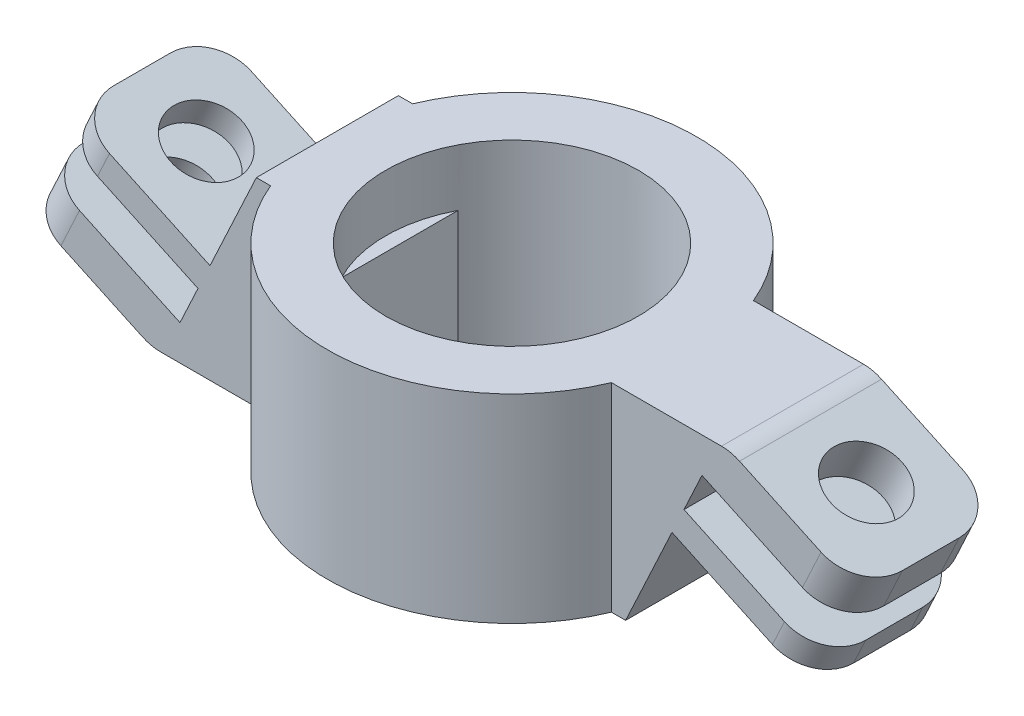
from build123d import *

# Parameters (mm, degrees)
SKETCH1_R           = 6.5
BOSS_EXTRUDE1_DEPTH = 7
BOSS_EXTRUDE2_DEPTH = 2.5
SKETCH3_R           = 1.25
CUT_EXTRUDE1_DEPTH  = 17.888639434
SKETCH4_R           = 1.25
CUT_EXTRUDE2_DEPTH  = 17.888639434
FILLET1_R           = 1.5
SKETCH5_R           = 4.45
CUT_EXTRUDE3_DEPTH  = 2


with BuildPart() as part:
    # Sketch1 → Boss-Extrude1 (new body)
    with BuildSketch(Plane(origin=(0, 0, 0), x_dir=(1, 0, 0), z_dir=(0, 1, 0))):
        Circle(SKETCH1_R)
        with BuildLine():
            Line((-3.95, 2.049390153), (-3.95, -2.049390153))
            ThreePointArc((-3.95, -2.049390153), (0, -4.45), (3.95, -2.049390153))
            Line((3.95, -2.049390153), (3.95, 2.049390153))
            ThreePointArc((3.95, 2.049390153), (0, 4.45), (-3.95, 2.049390153))
        make_face(mode=Mode.SUBTRACT)
    extrude(amount=BOSS_EXTRUDE1_DEPTH)

    # Sketch2 → Boss-Extrude2 (add, symmetric)
    with BuildSketch(Plane.XY):
        Polygon((5.5, 7), (5.5, 0), (6.5, 0), (8.132076804, 3.5), (13.029353969, 1.216362154), (13.45197223, 2.122669941), (8.554695065, 4.406307787), (9.188622458, 5.765769468), (14.085899623, 3.482131621), (14.740957929, 4.886908691), (10.209418994, 7), align=None)
        Polygon((-5.5, 0), (-5.5, 7), (-6.5, 7), (-8.132076804, 3.5), (-13.029353969, 5.783637846), (-13.45197223, 4.877330059), (-8.554695065, 2.593692213), (-9.188622458, 1.234230532), (-14.085899623, 3.517868379), (-14.740957929, 2.113091309), (-10.209418994, 0), align=None)
    extrude(amount=BOSS_EXTRUDE2_DEPTH, both=True)

    # Sketch3 → Cut-Extrude1 (cut, through all)
    with BuildSketch(Plane(origin=(4.504621032, 9.660190978, 0), x_dir=(0.906307787, -0.422618262, 0), z_dir=(0.422618262, 0.906307787, 0))):
        with Locations((8.794548103, 0)):
            Circle(SKETCH3_R)
    extrude(amount=-CUT_EXTRUDE1_DEPTH, mode=Mode.SUBTRACT)

    # Sketch4 → Cut-Extrude2 (cut, through all)
    with BuildSketch(Plane(origin=(-1.823465481, -3.910434344, 0), x_dir=(0.906307787, -0.422618262, 0), z_dir=(-0.422618262, -0.906307787, 0))):
        with Locations((-11.752875935, 0)):
            Circle(SKETCH4_R)
    extrude(amount=-CUT_EXTRUDE2_DEPTH, mode=Mode.SUBTRACT)

    # Fillet1
    fillet1_edges = [part.edges().sort_by_distance(p)[0] for p in [
        (13.2406631, 1.669516047, 2.5),
        (14.413428776, 4.184520156, 2.5),
        (10.209418994, 7, 0),
        (13.2406631, 1.669516047, -2.5),
        (14.413428776, 4.184520156, -2.5),
        (-13.2406631, 5.330483953, 2.5),
        (-14.413428776, 2.815479844, 2.5),
        (-14.413428776, 2.815479844, -2.5),
        (-10.209418994, 0, 0),
        (-13.2406631, 5.330483953, -2.5),
    ]]
    fillet(fillet1_edges, radius=FILLET1_R)

    # Sketch5 → Cut-Extrude3 (cut)
    with BuildSketch(Plane(origin=(0, 7, 0), x_dir=(1, 0, 0), z_dir=(0, 1, 0))):
        Circle(SKETCH5_R)
    extrude(amount=-CUT_EXTRUDE3_DEPTH, mode=Mode.SUBTRACT)


solid = part.part
